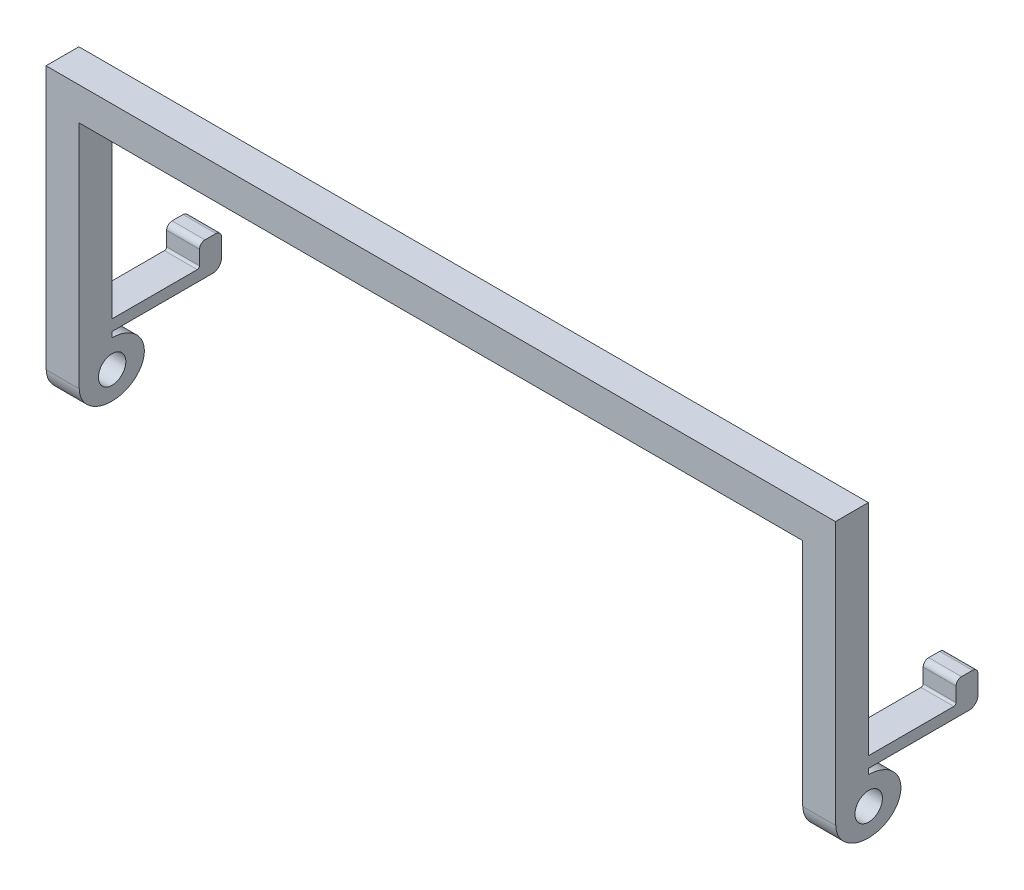
from build123d import *

# Parameters (mm, degrees)
SKETCH1_W               = 36
SKETCH1_H               = 3
BOSS_EXTRUDE1_DEPTH     = 3
BOSS_EXTRUDE2_DEPTH     = 3
SKETCH3_R               = 1.25
CUT_EXTRUDE1_DEPTH      = 1.0000001
CUT_EXTRUDE1_DEPTH_BACK = 73.0000001


with BuildPart() as part:
    # Sketch1 → Boss-Extrude1 (new body)
    with BuildSketch(Plane.XY):
        with Locations((18, 1.5)):
            Rectangle(SKETCH1_W, SKETCH1_H)
    boss_extrude1 = extrude(amount=BOSS_EXTRUDE1_DEPTH)

    # Sketch2 → Boss-Extrude2 (add)
    with BuildSketch(Plane(origin=(36, 0, 0), x_dir=(0, 0, -1), z_dir=(1, 0, 0))):
        with BuildLine():
            Line((0, -17), (7.8, -17))
            ThreePointArc((7.8, -17), (7.941421356, -16.941421356), (8, -16.8))
            Line((8, -16.8), (8, -15.5))
            ThreePointArc((8, -15.5), (8.146446609, -15.146446609), (8.5, -15))
            Line((8.5, -15), (9.5, -15))
            ThreePointArc((9.5, -15), (9.853553391, -15.146446609), (10, -15.5))
            Line((10, -15.5), (10, -17.2))
            ThreePointArc((10, -17.2), (9.765685425, -17.765685425), (9.2, -18))
            Line((9.2, -18), (0, -18))
            Line((0, -18), (0, -18.5))
            add(Edge.make_bspline(
                [(-2.969127625, -21), (-2.969127625, -27.035533906), (2.099490278, -22.767766953), (7.16810818, -18.5), (0, -18.5)],
                knots=[3.141592654, 3.141592654, 3.141592654, 5.497787144, 5.497787144, 7.853981634, 7.853981634, 7.853981634], degree=2, weights=[1, 0.382683432, 1, 0.382683432, 1]))
            Line((-2.969127625, -21), (-3, -21))
            Line((-3, -21), (-3, 3))
            Line((-3, 3), (0, 3))
            Line((0, 3), (0, -17))
        make_face()
    boss_extrude2 = extrude(amount=-BOSS_EXTRUDE2_DEPTH)

    # Mirror1: Boss-Extrude1, Boss-Extrude2 across plane
    add(boss_extrude1.mirror(Plane(origin=(0, 0, 3), x_dir=(0, 0, 1), z_dir=(1, 0, 0))))
    add(boss_extrude2.mirror(Plane(origin=(0, 0, 3), x_dir=(0, 0, 1), z_dir=(1, 0, 0))))

    # Sketch3 → Cut-Extrude1 (cut, two sides)
    with BuildSketch(Plane(origin=(36, 0, 0), x_dir=(0, 0, -1), z_dir=(1, 0, 0))) as cut_extrude1_sk:
        with Locations((0.030872375, -21)):
            Circle(SKETCH3_R)
    extrude(amount=CUT_EXTRUDE1_DEPTH, mode=Mode.SUBTRACT)
    extrude(cut_extrude1_sk.sketch, amount=-CUT_EXTRUDE1_DEPTH_BACK, mode=Mode.SUBTRACT)


solid = part.part
